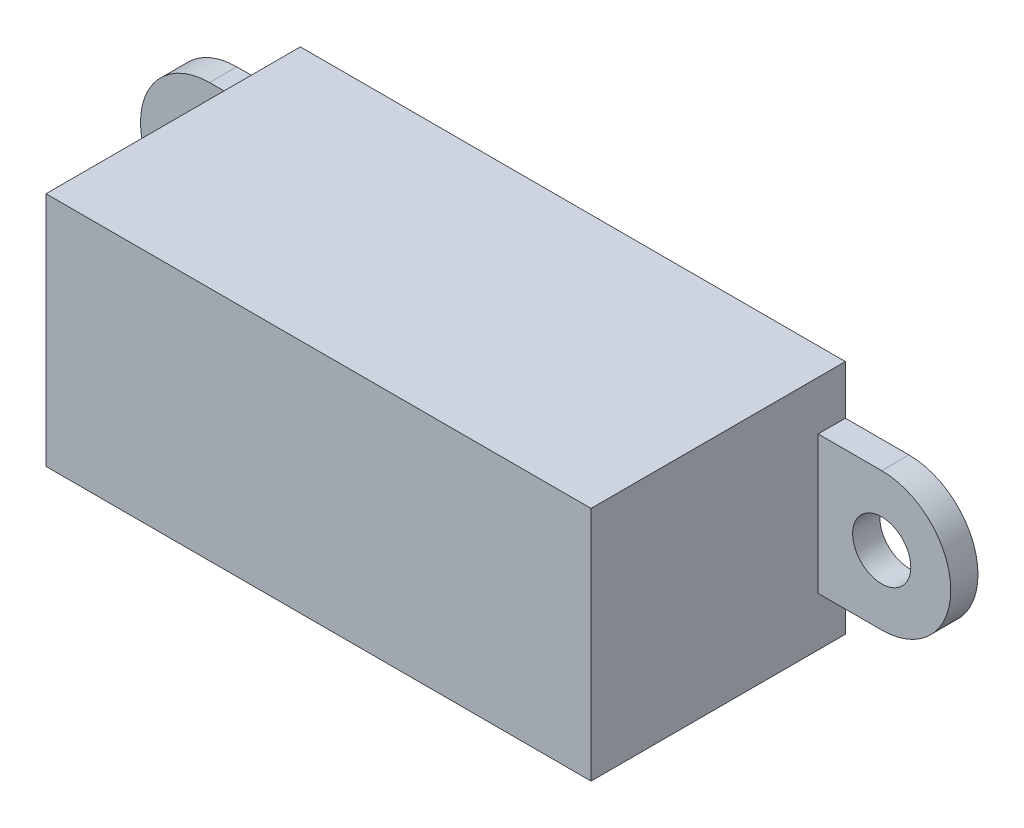
from build123d import *

# Parameters (mm, degrees)
SKETCH1_W           = 30
SKETCH1_H           = 13
BOSS_EXTRUDE1_DEPTH = 14
SKETCH2_R           = 1.6
BOSS_EXTRUDE2_DEPTH = 1.5


with BuildPart() as part:
    # Sketch1 → Boss-Extrude1 (new body)
    with BuildSketch(Plane.XY):
        Rectangle(SKETCH1_W, SKETCH1_H)
    extrude(amount=BOSS_EXTRUDE1_DEPTH)

    # Sketch2 → Boss-Extrude2 (add)
    with BuildSketch(Plane.XY):
        with BuildLine():
            Line((15, -3.8), (15, 3.8))
            Line((15, 3.8), (18.5, 3.8))
            ThreePointArc((18.5, 3.8), (22.3, 0), (18.5, -3.8))
            Line((18.5, -3.8), (15, -3.8))
        make_face()
        with Locations((18.5, 0)):
            Circle(SKETCH2_R, mode=Mode.SUBTRACT)
    boss_extrude2 = extrude(amount=BOSS_EXTRUDE2_DEPTH)

    # Mirror1: Boss-Extrude2 across plane
    add(boss_extrude2.mirror(Plane(origin=(0, 0, 0), x_dir=(0, 0, 1), z_dir=(1, 0, 0))))


solid = part.part
